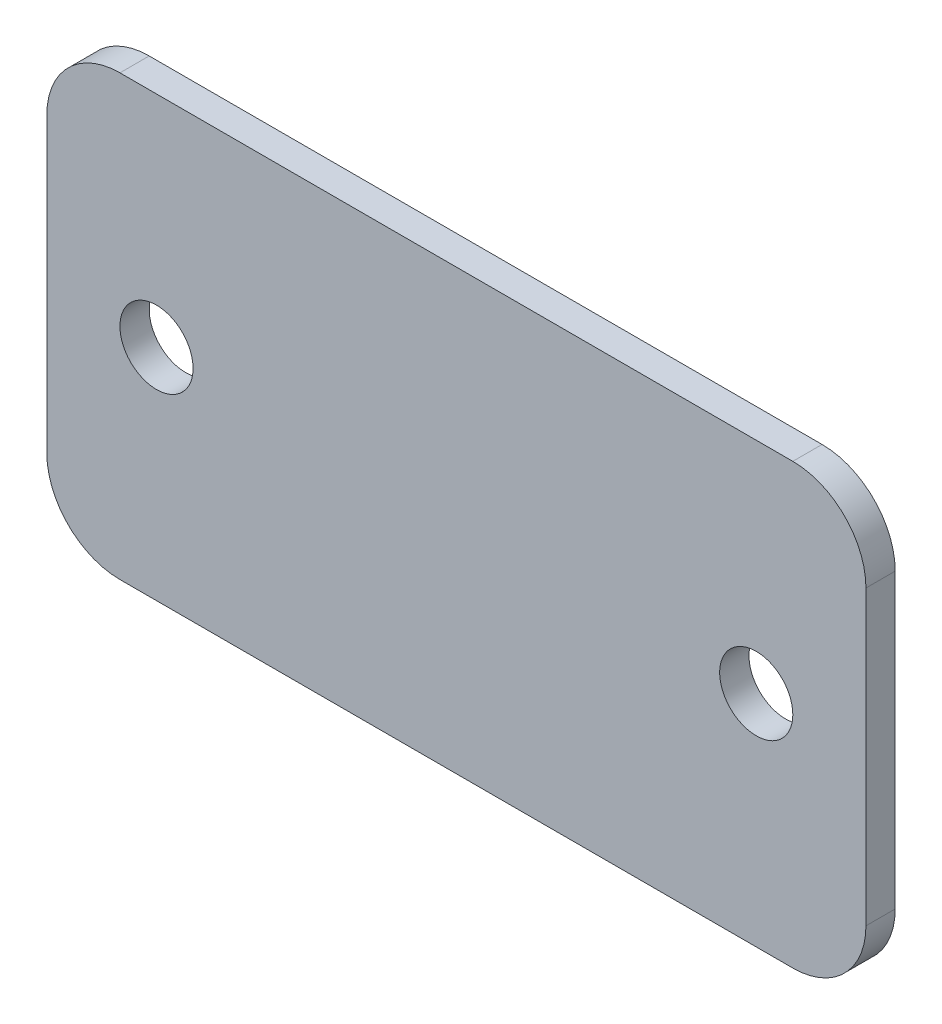
from build123d import *

# Parameters (mm, degrees)
ESQUISSE1_R        = 5
BOSS_EXTRU_1_DEPTH = 4


with BuildPart() as part:
    # Esquisse1 → Boss.-Extru.1 (new body)
    with BuildSketch(Plane.XY):
        with BuildLine():
            Line((46, -30), (-46, -30))
            ThreePointArc((-46, -30), (-53.071067812, -27.071067812), (-56, -20))
            Line((-56, -20), (-56, 20))
            ThreePointArc((-56, 20), (-53.071067812, 27.071067812), (-46, 30))
            Line((-46, 30), (46, 30))
            ThreePointArc((46, 30), (53.071067812, 27.071067812), (56, 20))
            Line((56, 20), (56, -20))
            ThreePointArc((56, -20), (53.071067812, -27.071067812), (46, -30))
        make_face()
        with Locations((-41, 0)):
            Circle(ESQUISSE1_R, mode=Mode.SUBTRACT)
        with Locations((41, 0)):
            Circle(ESQUISSE1_R, mode=Mode.SUBTRACT)
    extrude(amount=BOSS_EXTRU_1_DEPTH)


solid = part.part
